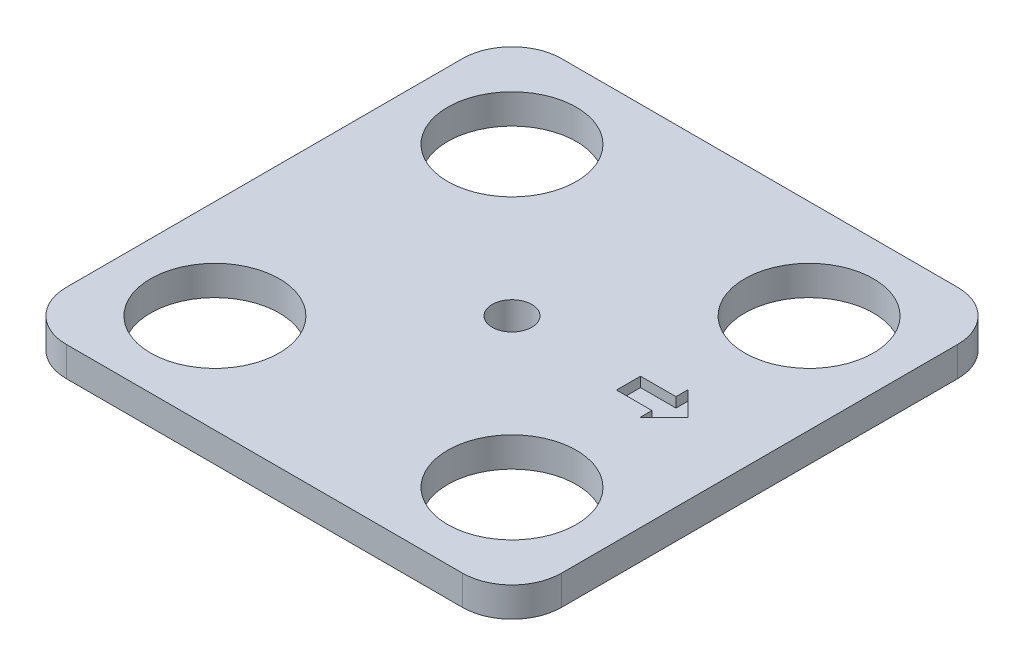
from build123d import *

# Parameters (mm, degrees)
SKETCH_1_W          = 500
SKETCH_1_H          = 500
EXTRUDE_1_DEPTH     = 30
SKETCH_2_R          = 65
CUT_EXTRUDE_1_DEPTH = 30
FILLET_1_R          = 50
CUT_EXTRUDE_2_DEPTH = 10
SKETCH_4_R          = 20
CUT_EXTRUDE_3_DEPTH = 31


with BuildPart() as part:
    # 草图1 → 凸台-拉伸1 (new body)
    with BuildSketch(Plane(origin=(0, 0, 0), x_dir=(1, 0, 0), z_dir=(0, 1, 0))):
        Rectangle(SKETCH_1_W, SKETCH_1_H)
    extrude(amount=EXTRUDE_1_DEPTH)

    # 草图2 → 切除-拉伸1 (cut)
    with BuildSketch(Plane(origin=(0, 30, 0), x_dir=(1, 0, 0), z_dir=(0, 1, 0))):
        with Locations((150, -150)):
            Circle(SKETCH_2_R)
        with Locations((-150, -150)):
            Circle(SKETCH_2_R)
        with Locations((150, 150)):
            Circle(SKETCH_2_R)
        with Locations((-150, 150)):
            Circle(SKETCH_2_R)
    extrude(amount=-CUT_EXTRUDE_1_DEPTH, mode=Mode.SUBTRACT)

    # 圆角1
    fillet_1_edges = [part.edges().sort_by_distance(p)[0] for p in [
        (-250, 15, -250),
        (250, 15, -250),
        (250, 15, 250),
        (-250, 15, 250),
    ]]
    fillet(fillet_1_edges, radius=FILLET_1_R)

    # 草图3 → 切除-拉伸2 (cut)
    with BuildSketch(Plane(origin=(0, 30, 0), x_dir=(1, 0, 0), z_dir=(0, 1, 0))):
        Polygon((177.720371549, 0), (153.455288688, 24.265082861), (153.455288688, 12.13254143), (117.643810746, 12.13254143), (117.643810746, -12.13254143), (153.455288688, -12.13254143), (153.455288688, -24.265082861), align=None)
    extrude(amount=-CUT_EXTRUDE_2_DEPTH, mode=Mode.SUBTRACT)

    # 草图4 → 切除-拉伸3 (cut, through all)
    with BuildSketch(Plane(origin=(0, 30, 0), x_dir=(1, 0, 0), z_dir=(0, 1, 0))):
        Circle(SKETCH_4_R)
    extrude(amount=-CUT_EXTRUDE_3_DEPTH, mode=Mode.SUBTRACT)


solid = part.part
